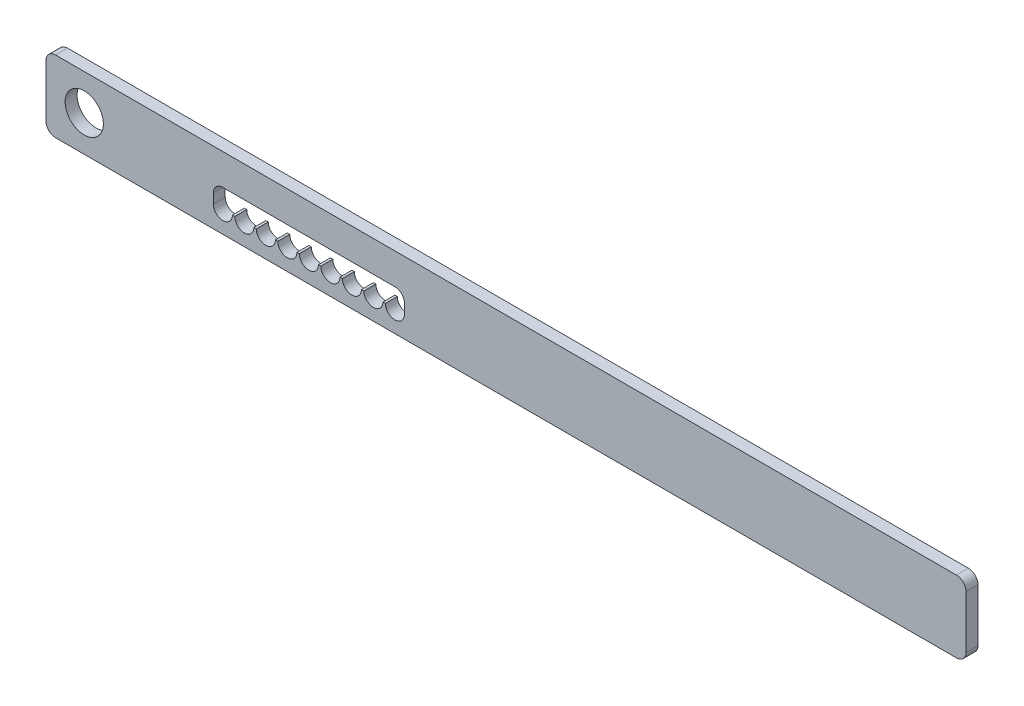
from build123d import *

# Parameters (mm, degrees)
PLAT_W                      = 30
PLAT_H                      = 5
EL_MENT_M_CANO_SOUD_1_DEPTH = 385
ESQUISSE2_R                 = 8
ENL_V_MAT_EXTRU_1_DEPTH     = 10
ESQUISSE3_W                 = 80
ESQUISSE3_H                 = 8
ENL_V_MAT_EXTRU_2_DEPTH     = 10
CONG_1_R                    = 4
ESQUISSE4_R                 = 4
ENL_V_MAT_EXTRU_3_DEPTH     = 10
R_P_TITION_LIN_AIRE1_COUNT  = 9
R_P_TITION_LIN_AIRE1_PITCH  = 9
CONG_2_R                    = 4


with BuildPart() as part:
    # plat → Elément mécano-soudé1 (new body)
    with BuildSketch(Plane.YZ.offset(-192.5)):
        Rectangle(PLAT_W, PLAT_H)
    extrude(amount=EL_MENT_M_CANO_SOUD_1_DEPTH)

    # Esquisse2 → Enlèv. mat.-Extru.1 (cut)
    with BuildSketch(Plane.XY.offset(2.5)):
        with Locations((-176.5, 0)):
            Circle(ESQUISSE2_R)
    extrude(amount=-ENL_V_MAT_EXTRU_1_DEPTH, mode=Mode.SUBTRACT)

    # Esquisse3 → Enlèv. mat.-Extru.2 (cut)
    with BuildSketch(Plane.XY.offset(2.5)):
        with Locations((-82.5, -2)):
            Rectangle(ESQUISSE3_W, ESQUISSE3_H)
    extrude(amount=-ENL_V_MAT_EXTRU_2_DEPTH, mode=Mode.SUBTRACT)

    # Congé1
    cong_1_edges = [part.edges().sort_by_distance(p)[0] for p in [
        (-42.5, 2, 0),
        (-122.5, 2, 0),
    ]]
    fillet(cong_1_edges, radius=CONG_1_R)

    # Esquisse4 → Enlèv. mat.-Extru.3 (cut)
    with BuildSketch(Plane.XY.offset(2.5)):
        with Locations((-118.5, -6)):
            Circle(ESQUISSE4_R)
    enl_v_mat_extru_3 = extrude(amount=-ENL_V_MAT_EXTRU_3_DEPTH, mode=Mode.SUBTRACT)

    # Répétition linéaire1: Enlèv. mat.-Extru.3 ×9
    with Locations(*[(i * R_P_TITION_LIN_AIRE1_PITCH, 0, 0) for i in range(1, R_P_TITION_LIN_AIRE1_COUNT)]):
        add(enl_v_mat_extru_3, mode=Mode.SUBTRACT)

    # Congé2
    cong_2_edges = [part.edges().sort_by_distance(p)[0] for p in [
        (192.5, 15, 0),
        (192.5, -15, 0),
        (-192.5, 15, 0),
        (-192.5, -15, 0),
    ]]
    fillet(cong_2_edges, radius=CONG_2_R)


solid = part.part
